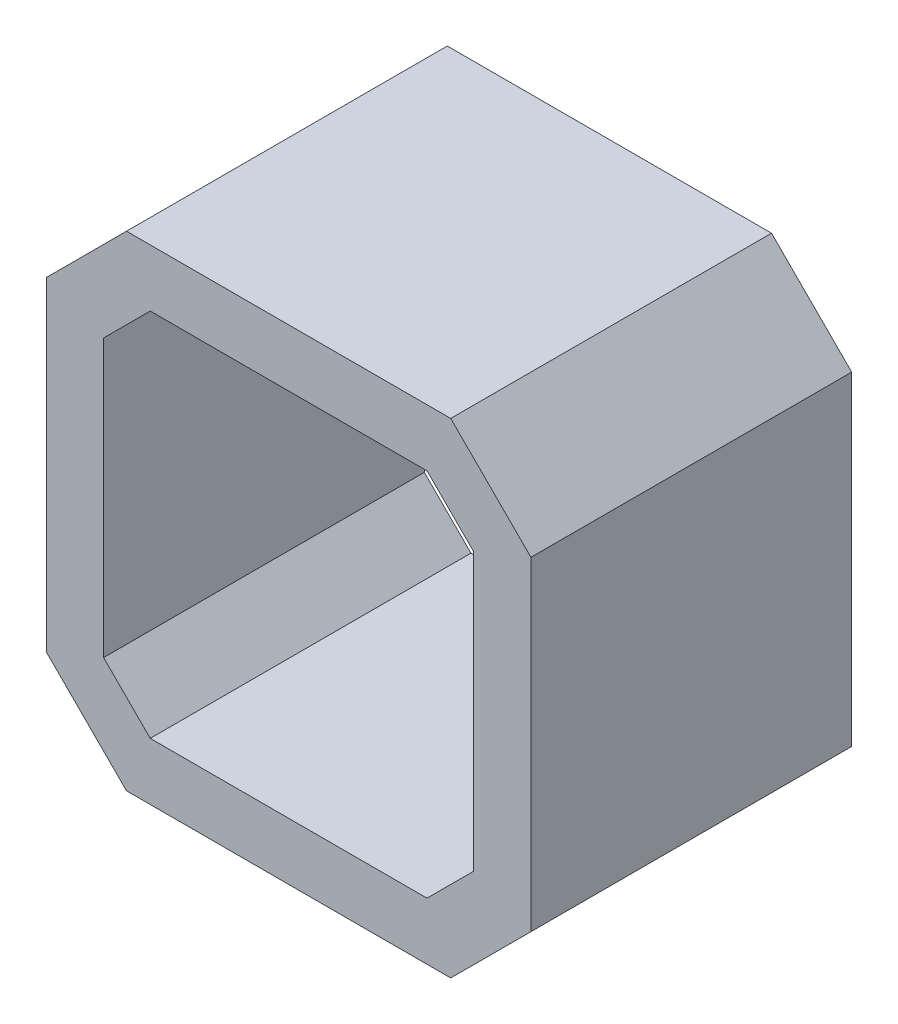
from build123d import *

# Parameters (mm, degrees)
BODY_DEPTH = 28


with BuildPart() as part:
    # Sketch1 → Body (new body)
    with BuildSketch(Plane.XY):
        Polygon((-21.15, 14.15), (-14.15, 21.15), (14.15, 21.15), (21.15, 14.15), (21.15, -14.15), (14.15, -21.15), (-14.15, -21.15), (-21.15, -14.15), align=None)
        Polygon((-12.078932188, 16.15), (12.078932188, 16.15), (16.15, 12.078932188), (16.15, -12.078932188), (12.078932188, -16.15), (-12.078932188, -16.15), (-16.15, -12.078932188), (-16.15, 12.078932188), align=None, mode=Mode.SUBTRACT)
    extrude(amount=BODY_DEPTH)


solid = part.part
